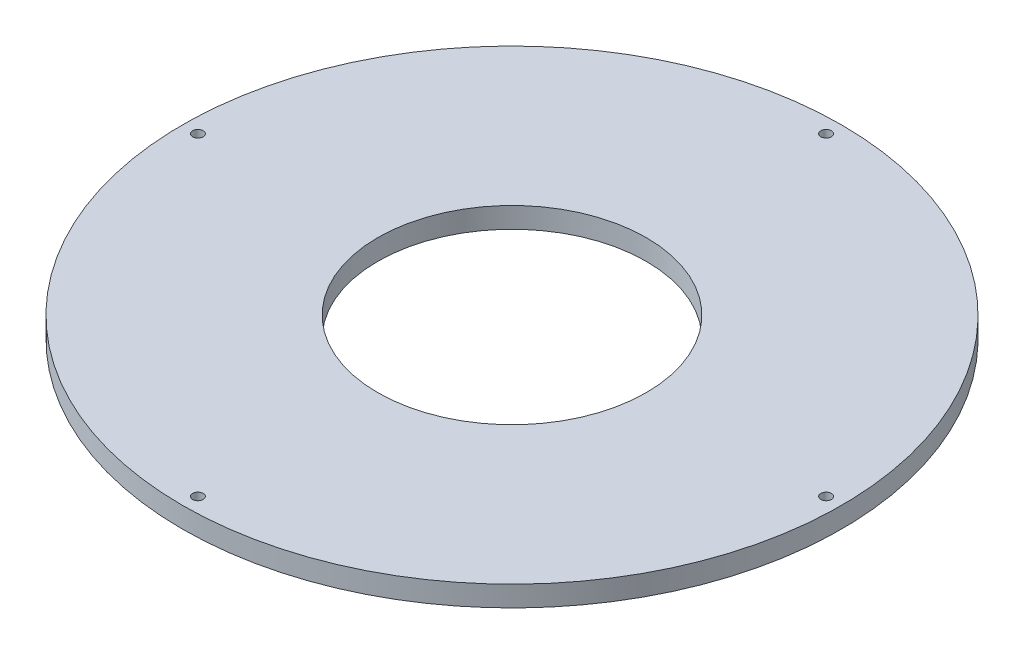
from build123d import *

# Parameters (mm, degrees)
SKETCH1_R             = 101.6
SKETCH1_R_2           = 41.402
BOSS_EXTRUDE1_DEPTH   = 6.35
F_4_CLEARANCE_HOLE1_D = 3.2639


with BuildPart() as part:
    # Sketch1 → Boss-Extrude1 (new body)
    with BuildSketch(Plane(origin=(0, 0, 0), x_dir=(1, 0, 0), z_dir=(0, 1, 0))):
        with Locations(Location((0, 0, 0), (0, 0, 270))):  # turned: the seam where the file's is
            Circle(SKETCH1_R)
        with Locations(Location((0, 0, 0), (0, 0, 270))):  # turned: the seam where the file's is
            Circle(SKETCH1_R_2, mode=Mode.SUBTRACT)
    extrude(amount=BOSS_EXTRUDE1_DEPTH)

    # #4 Clearance Hole1 (through all)
    with Locations(Plane(origin=(0, 6.35, 0), x_dir=(1, 0, 0), z_dir=(0, 1, 0))):
        with Locations((0, 96.8375), (96.8375, 0), (0, -96.8375), (-96.8375, 0)):
            Hole(F_4_CLEARANCE_HOLE1_D / 2)


solid = part.part
